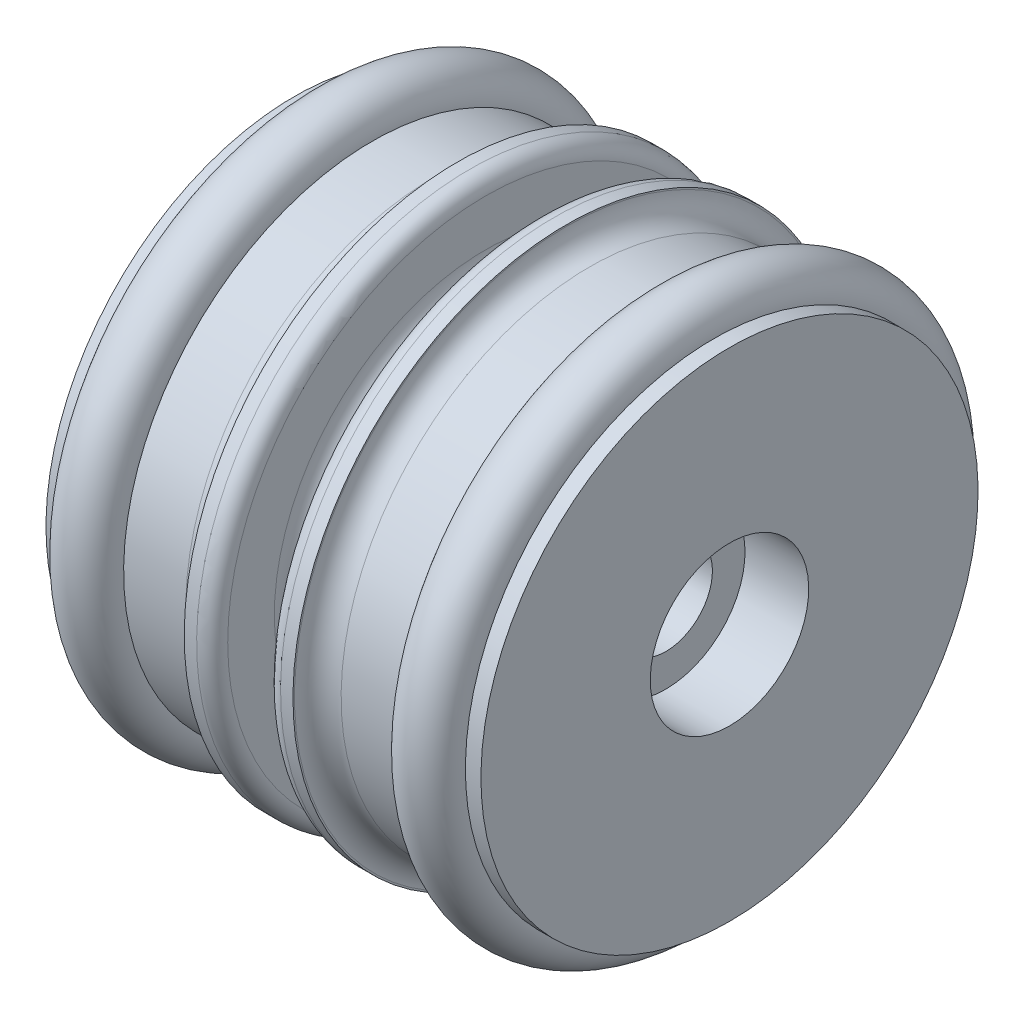
from build123d import *

# Parameters (mm, degrees)
SKETCH_1_R = 1.95


with BuildPart() as part:
    # 草图1 → 旋转1 (revolve)
    with BuildSketch(Plane.XY):
        with Locations((3.300391272, 16)):
            Circle(SKETCH_1_R)
        with Locations((25.300391272, 16)):
            Circle(SKETCH_1_R)
        with BuildLine():
            Line((17.800391272, 17.5), (17.800391272, 17.6))
            Line((17.800391272, 17.6), (17.000391272, 17.6))
            ThreePointArc((17.000391272, 17.6), (16.293284491, 17.307106781), (16.000391272, 16.6))
            Line((16.000391272, 16.6), (16.000391272, 13.6))
            ThreePointArc((16.000391272, 13.6), (15.561051444, 12.539339828), (14.500391272, 12.1))
            Line((14.500391272, 12.1), (14.100391272, 12.1))
            ThreePointArc((14.100391272, 12.1), (13.0397311, 12.539339828), (12.600391272, 13.6))
            Line((12.600391272, 13.6), (12.600391272, 16.6))
            ThreePointArc((12.600391272, 16.6), (12.307498053, 17.307106781), (11.600391272, 17.6))
            Line((11.600391272, 17.6), (10.800391272, 17.6))
            Line((10.800391272, 17.6), (10.800391272, 17.5))
            ThreePointArc((10.800391272, 17.5), (10.361051444, 16.439339828), (9.300391272, 16))
            Line((9.300391272, 16), (5.300391272, 16))
            ThreePointArc((5.300391272, 16), (3.300391272, 14), (1.300391272, 16))
            Line((1.300391272, 16), (0.300391272, 16))
            Line((0.300391272, 16), (0.300391272, 5.1))
            Line((0.300391272, 5.1), (4.400391272, 5.1))
            Line((4.400391272, 5.1), (4.400391272, 3))
            Line((4.400391272, 3), (24.200391272, 3))
            Line((24.200391272, 3), (24.200391272, 5.1))
            Line((24.200391272, 5.1), (28.300391272, 5.1))
            Line((28.300391272, 5.1), (28.300391272, 16))
            Line((28.300391272, 16), (27.300391272, 16))
            ThreePointArc((27.300391272, 16), (25.300391272, 14), (23.300391272, 16))
            Line((23.300391272, 16), (19.300391272, 16))
            ThreePointArc((19.300391272, 16), (18.2397311, 16.439339828), (17.800391272, 17.5))
        make_face()
    revolve(axis=Axis((0, 0, 0), (1, 0, 0)))


solid = part.part
